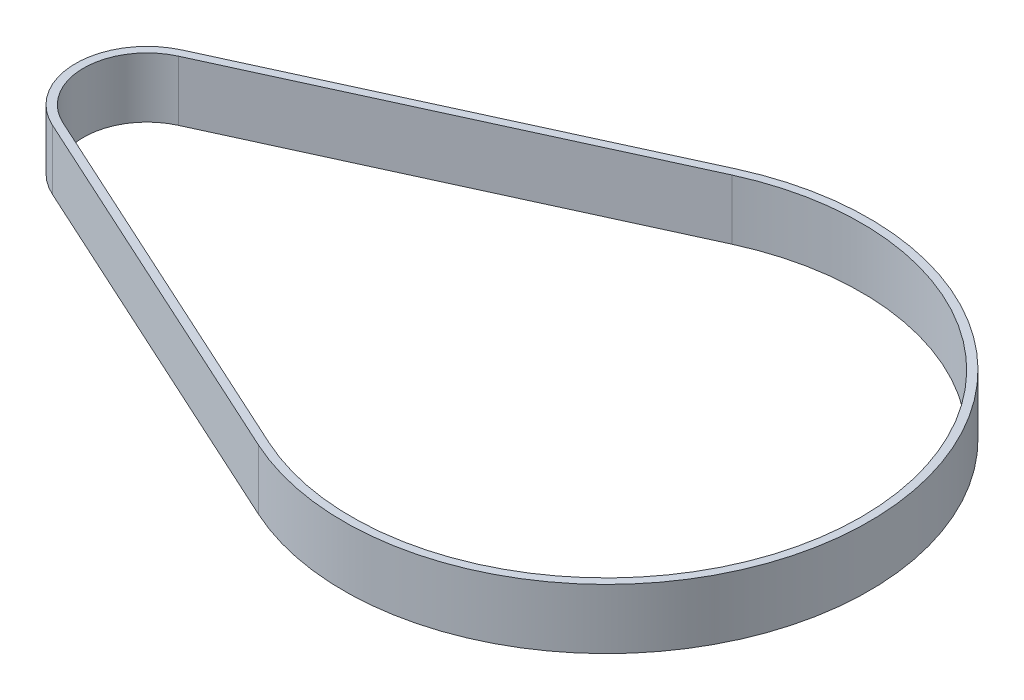
from build123d import *

# Parameters (mm, degrees)
BOSS_EXTRUDE1_DEPTH = 6


with BuildPart() as part:
    # Sketch1 → Boss-Extrude1 (new body)
    with BuildSketch(Plane(origin=(0, 0, 0), x_dir=(1, 0, 0), z_dir=(0, 1, 0))):
        with BuildLine():
            Line((-48.976576087, 6.500961067), (-10.948804348, 23.912626024))
            ThreePointArc((-10.948804348, 23.912626024), (26.3, 0), (-10.948804348, -23.912626024))
            Line((-10.948804348, -23.912626024), (-48.976576087, -6.500961067))
            ThreePointArc((-48.976576087, -6.500961067), (-53.15, 0), (-48.976576087, 6.500961067))
        make_face()
        with BuildLine():
            Line((-48.643532609, 5.773580808), (-10.61576087, 23.185245764))
            ThreePointArc((-10.61576087, 23.185245764), (25.5, 0), (-10.61576087, -23.185245764))
            Line((-10.61576087, -23.185245764), (-48.643532609, -5.773580808))
            ThreePointArc((-48.643532609, -5.773580808), (-52.35, 0), (-48.643532609, 5.773580808))
        make_face(mode=Mode.SUBTRACT)
    extrude(amount=BOSS_EXTRUDE1_DEPTH)


solid = part.part
